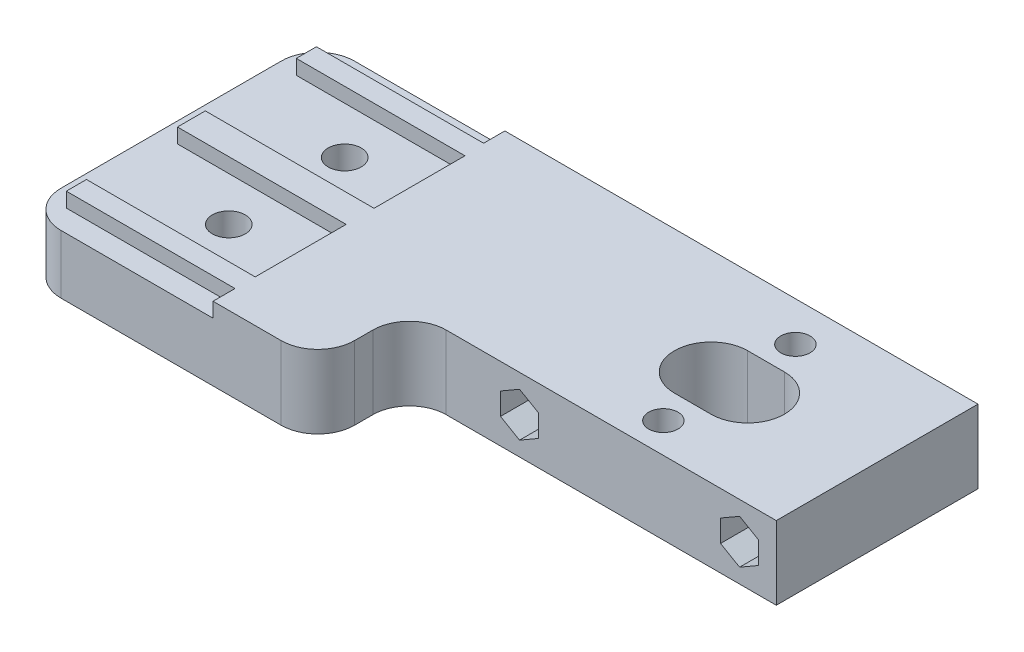
from build123d import *

# Parameters (mm, degrees)
SKETCH1_W            = 90
SKETCH1_H            = 27.5
BOSS_EXTRUDE1_DEPTH  = 10
CUT_EXTRUDE1_DEPTH   = 28.5
SKETCH9_W            = 40
SKETCH9_H            = 40
BOSS_EXTRUDE3_DEPTH  = 10
CUT_EXTRUDE2_DEPTH   = 2
M4_CLEARANCE_HOLE1_D = 4.5
FILLET1_R            = 5
SKETCH10_R           = 2
CUT_EXTRUDE3_DEPTH   = 11


with BuildPart() as part:
    # Sketch1 → Boss-Extrude1 (new body)
    with BuildSketch(Plane(origin=(0, 0, 0), x_dir=(1, 0, 0), z_dir=(0, 1, 0))):
        with Locations((-45, 13.75)):
            Rectangle(SKETCH1_W, SKETCH1_H)
    extrude(amount=BOSS_EXTRUDE1_DEPTH)

    # Sketch2 → Cut-Extrude1 (cut, through all)
    with BuildSketch(Plane.XY):
        Polygon((-32.4, 3.4988893), (-32.4, 6.5011107), (-35, 8.0022214), (-37.6, 6.5011107), (-37.6, 3.4988893), (-35, 1.9977786), align=None)
        Polygon((-2.4, 3.4988893), (-2.4, 6.5011107), (-5, 8.0022214), (-7.6, 6.5011107), (-7.6, 3.4988893), (-5, 1.9977786), align=None)
    extrude(amount=-CUT_EXTRUDE1_DEPTH, mode=Mode.SUBTRACT)

    # Sketch9 → Boss-Extrude3 (add)
    with BuildSketch(Plane(origin=(0, 10, 0), x_dir=(1, 0, 0), z_dir=(0, 1, 0))):
        with Locations((-70, 7.5)):
            Rectangle(SKETCH9_W, SKETCH9_H)
    extrude(amount=-BOSS_EXTRUDE3_DEPTH)

    # Sketch4 → Cut-Extrude2 (cut)
    with BuildSketch(Plane(origin=(-50, 10, 0), x_dir=(0, 0, -1), z_dir=(0, 1, 0))):
        Polygon((27.6, 44.841124336), (27.6, 37.258569022), (27.6, 14.504295037), (24.6, 14.504295037), (24.6, 37.289189868), (21.85, 37.289189868), (21.85, 30.489189868), (21.85, 14.289189868), (9.45, 14.289189868), (9.45, 30.489189868), (9.45, 37.289189868), (5.65, 37.289189868), (5.65, 30.489189868), (5.65, 14.289189868), (-6.75, 14.289189868), (-6.75, 30.489189868), (-6.75, 37.289189868), (-9.5, 37.289189868), (-9.5, 14.289189868), (-12.5, 14.289189868), (-12.5, 37.289189868), (-12.5, 44.841124336), align=None)
    extrude(amount=-CUT_EXTRUDE2_DEPTH, mode=Mode.SUBTRACT)

    # M4 Clearance Hole1 (through all)
    with Locations(Plane(origin=(0, 8, 0), x_dir=(0, 0, -1), z_dir=(0, 1, 0))):
        with Locations((-0.35, 74.289189868), (15.45, 74.289189868)):
            Hole(M4_CLEARANCE_HOLE1_D / 2)

    # Fillet1
    fillet1_edges = [part.edges().sort_by_distance(p)[0] for p in [
        (-90, 4, 12.5),
        (-50, 5, 0),
        (-50, 5, 12.5),
        (-90, 4, -27.5),
    ]]
    fillet(fillet1_edges, radius=FILLET1_R)

    # Sketch10 → Cut-Extrude3 (cut, through all)
    with BuildSketch(Plane(origin=(0, 10, 0), x_dir=(1, 0, 0), z_dir=(0, 1, 0))):
        with Locations((-19.5, 4.106184291)):
            Circle(SKETCH10_R)
        with Locations((-19.5, 22.106184291)):
            Circle(SKETCH10_R)
        with BuildLine():
            Line((-17, 8.106184291), (-22, 8.106184291))
            ThreePointArc((-22, 8.106184291), (-27, 13.106184291), (-22, 18.106184291))
            Line((-22, 18.106184291), (-17, 18.106184291))
            ThreePointArc((-17, 18.106184291), (-12, 13.106184291), (-17, 8.106184291))
        make_face()
    extrude(amount=-CUT_EXTRUDE3_DEPTH, mode=Mode.SUBTRACT)


solid = part.part
